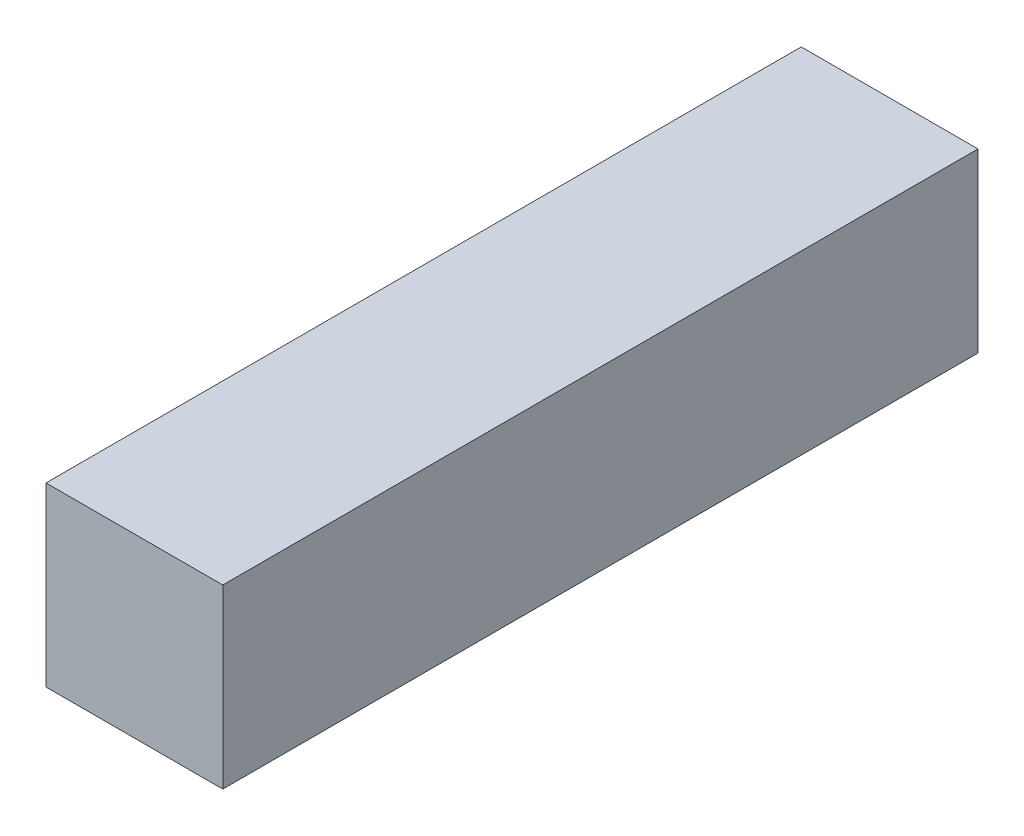
from build123d import *

# Parameters (mm, degrees)
SKETCH_1_W      = 27.9
SKETCH_1_H      = 119.2
EXTRUDE_1_DEPTH = 27.9


with BuildPart() as part:
    # Эскиз1 → Бобышка-Вытянуть1 (new body)
    with BuildSketch(Plane(origin=(0, 0, 0), x_dir=(1, 0, 0), z_dir=(0, 1, 0))):
        Rectangle(SKETCH_1_W, SKETCH_1_H)
    extrude(amount=EXTRUDE_1_DEPTH)


solid = part.part
